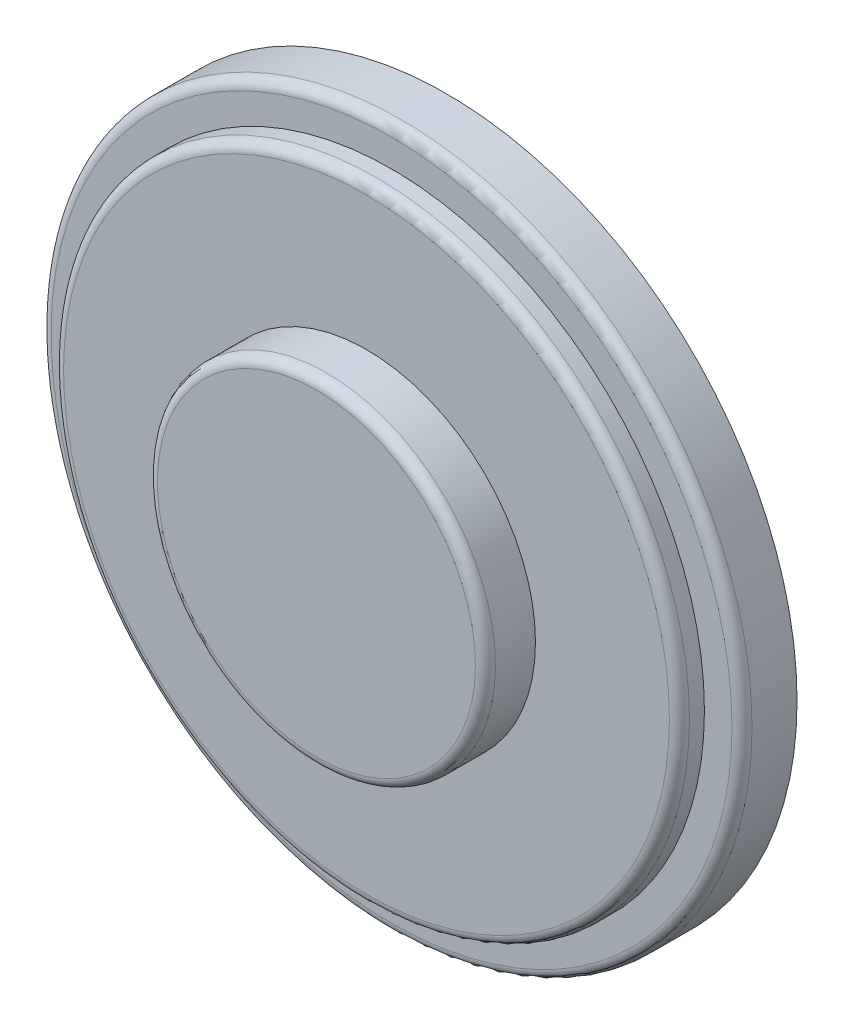
from build123d import *

# Parameters (mm, degrees)
SKETCH2_R           = 14
BOSS_EXTRUDE2_DEPTH = 2.2
SKETCH3_R           = 12.5
BOSS_EXTRUDE5_DEPTH = 3.2
SKETCH4_R           = 6.75
BOSS_EXTRUDE6_DEPTH = 5.2
FILLET1_R           = 0.4


with BuildPart() as part:
    # Sketch2 → Boss-Extrude2 (new body)
    with BuildSketch(Plane.XY):
        Circle(SKETCH2_R)
    extrude(amount=BOSS_EXTRUDE2_DEPTH)

    # Sketch3 → Boss-Extrude5 (add)
    with BuildSketch(Plane.XY):
        Circle(SKETCH3_R)
    extrude(amount=BOSS_EXTRUDE5_DEPTH)

    # Sketch4 → Boss-Extrude6 (add)
    with BuildSketch(Plane.XY):
        Circle(SKETCH4_R)
    extrude(amount=BOSS_EXTRUDE6_DEPTH)

    # Fillet1
    fillet1_edges = [part.edges().sort_by_distance(p)[0] for p in [
        (-6.75, 0, 5.2),
        (-14, 0, 2.2),
        (-12.5, 0, 3.2),
    ]]
    fillet(fillet1_edges, radius=FILLET1_R)


solid = part.part
